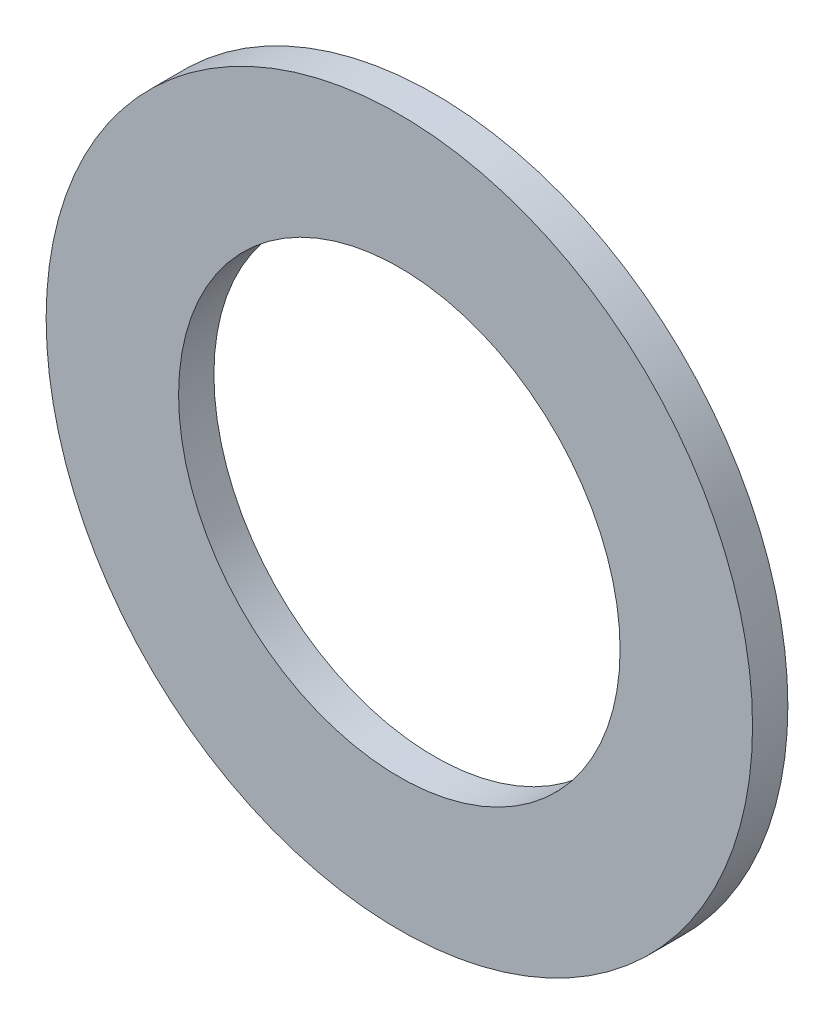
from build123d import *

# Parameters (mm, degrees)
SKETCH1_R           = 20
SKETCH1_R_2         = 12.5
BOSS_EXTRUDE1_DEPTH = 2


with BuildPart() as part:
    # Sketch1 → Boss-Extrude1 (new body)
    with BuildSketch(Plane.XY):
        Circle(SKETCH1_R)
        Circle(SKETCH1_R_2, mode=Mode.SUBTRACT)
    extrude(amount=BOSS_EXTRUDE1_DEPTH)


solid = part.part
